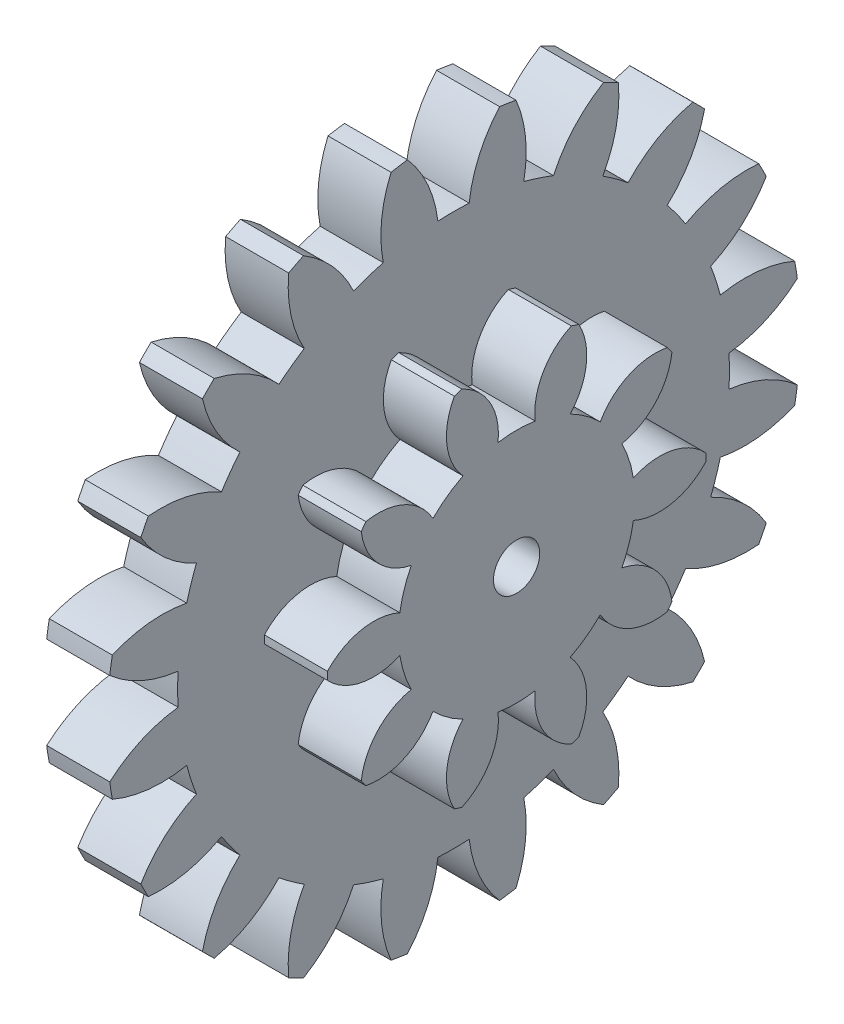
from build123d import *

# Parameters (mm, degrees)
SKETCH1_W                      = 3
SKETCH1_H                      = 16.5
CUT_EXTRUDE1_DEPTH             = 4
CUT_EXTRUDE2_DEPTH             = 4
CUT_EXTRUDE3_DEPTH             = 4
CUT_EXTRUDE4_DEPTH             = 4
CUT_EXTRUDE5_DEPTH             = 4
CUT_EXTRUDE6_DEPTH             = 4
CUT_EXTRUDE7_DEPTH             = 4
CUT_EXTRUDE8_DEPTH             = 4
CUT_EXTRUDE9_DEPTH             = 4
CUT_EXTRUDE10_DEPTH            = 4
CUT_EXTRUDE11_DEPTH            = 4
CUT_EXTRUDE12_DEPTH            = 4
CUT_EXTRUDE13_DEPTH            = 4
CUT_EXTRUDE14_DEPTH            = 4
CUT_EXTRUDE15_DEPTH            = 4
CUT_EXTRUDE16_DEPTH            = 4
CUT_EXTRUDE17_DEPTH            = 4
CUT_EXTRUDE18_DEPTH            = 4
CUT_EXTRUDE19_DEPTH            = 4
CUT_EXTRUDE20_DEPTH            = 4
BOSS_EXTRUDE1_DEPTH            = 3
F_2_2_2_2_DIAMETER_HOLE1_D     = 2.2
F_2_2_2_2_DIAMETER_HOLE1_DEPTH = 6


with BuildPart() as part:
    # Sketch1 → Revolve1 (revolve)
    with BuildSketch(Plane(origin=(0, 0, 4.89859854), x_dir=(-1, 0, 0), z_dir=(0, 0, -1))):
        with Locations((10.667145612, 10.018834535)):
            Rectangle(SKETCH1_W, SKETCH1_H)
    revolve(axis=Axis((-9.167145612, 1.768834535, 4.89859854), (-1, 0, 0)))

    # Sketch2 → Cut-Extrude1 (cut, through all)
    with BuildSketch(Plane.ZY.offset(12.167145612)):
        with BuildLine():
            ThreePointArc((-11.455448356, 3.958617656), (-11.60140146, 1.768834535), (-11.455448356, -0.420948587))
            ThreePointArc((-11.455448356, -0.420948587), (-9.939531335, 0.54858378), (-8.204306335, 1.025020154))
            ThreePointArc((-8.204306335, 1.025020154), (-8.22540146, 1.768834535), (-8.204306335, 2.512648915))
            ThreePointArc((-8.204306335, 2.512648915), (-9.939531335, 2.98908529), (-11.455448356, 3.958617656))
        make_face()
    extrude(amount=-CUT_EXTRUDE1_DEPTH, mode=Mode.SUBTRACT)

    # Sketch3 → Cut-Extrude2 (cut, through all)
    with BuildSketch(Plane.ZY.offset(12.167145612)):
        with BuildLine():
            ThreePointArc((-9.978344129, 8.905120459), (-10.793833978, 6.867614942), (-11.331704526, 4.739905445))
            ThreePointArc((-11.331704526, 4.739905445), (-9.590379788, 5.193541399), (-7.792855808, 5.110445303))
            ThreePointArc((-7.792855808, 5.110445303), (-7.583067179, 5.824373569), (-7.333153239, 6.52526433))
            ThreePointArc((-7.333153239, 6.52526433), (-8.836223347, 7.514596263), (-9.978344129, 8.905120459))
        make_face()
    extrude(amount=-CUT_EXTRUDE2_DEPTH, mode=Mode.SUBTRACT)

    # Sketch4 → Cut-Extrude3 (cut, through all)
    with BuildSketch(Plane.ZY.offset(12.167145612)):
        with BuildLine():
            ThreePointArc((-7.044981101, 13.153073875), (-8.450181867, 11.467291197), (-9.61922555, 9.609930356))
            ThreePointArc((-9.61922555, 9.609930356), (-7.822946092, 9.503264849), (-6.139077303, 8.868770308))
            ThreePointArc((-6.139077303, 8.868770308), (-5.718940494, 9.482928186), (-5.264671056, 10.072287257))
            ThreePointArc((-5.264671056, 10.072287257), (-6.388455296, 11.477672045), (-7.044981101, 13.153073875))
        make_face()
    extrude(amount=-CUT_EXTRUDE3_DEPTH, mode=Mode.SUBTRACT)

    # Sketch5 → Cut-Extrude4 (cut, through all)
    with BuildSketch(Plane.ZY.offset(12.167145612)):
        with BuildLine():
            ThreePointArc((-2.942497281, 16.286658625), (-4.799858122, 15.117614942), (-6.4856408, 13.712414176))
            ThreePointArc((-6.4856408, 13.712414176), (-4.81023897, 13.055888371), (-3.404854182, 11.932104131))
            ThreePointArc((-3.404854182, 11.932104131), (-2.815495111, 12.386373569), (-2.201337233, 12.806510377))
            ThreePointArc((-2.201337233, 12.806510377), (-2.835831774, 14.490379167), (-2.942497281, 16.286658625))
        make_face()
    extrude(amount=-CUT_EXTRUDE4_DEPTH, mode=Mode.SUBTRACT)

    # Sketch6 → Cut-Extrude5 (cut, through all)
    with BuildSketch(Plane.ZY.offset(12.167145612)):
        with BuildLine():
            ThreePointArc((1.92752763, 17.999137601), (-0.200181867, 17.461267053), (-2.237687384, 16.645777204))
            ThreePointArc((-2.237687384, 16.645777204), (-0.847163188, 15.503656422), (0.142168745, 14.000586314))
            ThreePointArc((0.142168745, 14.000586314), (0.843059506, 14.250500254), (1.556987772, 14.460288883))
            ThreePointArc((1.556987772, 14.460288883), (1.473891676, 16.257812863), (1.92752763, 17.999137601))
        make_face()
    extrude(amount=-CUT_EXTRUDE5_DEPTH, mode=Mode.SUBTRACT)

    # Sketch7 → Cut-Extrude6 (cut, through all)
    with BuildSketch(Plane.ZY.offset(12.167145612)):
        with BuildLine():
            ThreePointArc((7.088381662, 18.122881431), (4.89859854, 18.268834535), (2.708815419, 18.122881431))
            ThreePointArc((2.708815419, 18.122881431), (3.678347785, 16.60696441), (4.15478416, 14.87173941))
            ThreePointArc((4.15478416, 14.87173941), (4.89859854, 14.892834535), (5.642412921, 14.87173941))
            ThreePointArc((5.642412921, 14.87173941), (6.118849295, 16.60696441), (7.088381662, 18.122881431))
        make_face()
    extrude(amount=-CUT_EXTRUDE6_DEPTH, mode=Mode.SUBTRACT)

    # Sketch8 → Cut-Extrude7 (cut, through all)
    with BuildSketch(Plane.ZY.offset(12.167145612)):
        with BuildLine():
            ThreePointArc((12.034884465, 16.645777204), (9.997378948, 17.461267053), (7.869669451, 17.999137601))
            ThreePointArc((7.869669451, 17.999137601), (8.323305405, 16.257812863), (8.240209309, 14.460288883))
            ThreePointArc((8.240209309, 14.460288883), (8.954137575, 14.250500254), (9.655028336, 14.000586314))
            ThreePointArc((9.655028336, 14.000586314), (10.644360269, 15.503656422), (12.034884465, 16.645777204))
        make_face()
    extrude(amount=-CUT_EXTRUDE7_DEPTH, mode=Mode.SUBTRACT)

    # Sketch9 → Cut-Extrude8 (cut, through all)
    with BuildSketch(Plane.ZY.offset(12.167145612)):
        with BuildLine():
            ThreePointArc((16.282837881, 13.712414176), (14.597055203, 15.117614942), (12.739694362, 16.286658625))
            ThreePointArc((12.739694362, 16.286658625), (12.633028855, 14.490379167), (11.998534314, 12.806510377))
            ThreePointArc((11.998534314, 12.806510377), (12.612692192, 12.386373569), (13.202051263, 11.932104131))
            ThreePointArc((13.202051263, 11.932104131), (14.607436051, 13.055888371), (16.282837881, 13.712414176))
        make_face()
    extrude(amount=-CUT_EXTRUDE8_DEPTH, mode=Mode.SUBTRACT)

    # Sketch10 → Cut-Extrude9 (cut, through all)
    with BuildSketch(Plane.ZY.offset(12.167145612)):
        with BuildLine():
            ThreePointArc((19.416422631, 9.609930356), (18.247378948, 11.467291197), (16.842178182, 13.153073875))
            ThreePointArc((16.842178182, 13.153073875), (16.185652377, 11.477672045), (15.061868137, 10.072287257))
            ThreePointArc((15.061868137, 10.072287257), (15.516137575, 9.482928186), (15.936274383, 8.868770308))
            ThreePointArc((15.936274383, 8.868770308), (17.620143173, 9.503264849), (19.416422631, 9.609930356))
        make_face()
    extrude(amount=-CUT_EXTRUDE9_DEPTH, mode=Mode.SUBTRACT)

    # Sketch11 → Cut-Extrude10 (cut, through all)
    with BuildSketch(Plane.ZY.offset(12.167145612)):
        with BuildLine():
            ThreePointArc((21.128901607, 4.739905445), (20.591031059, 6.867614942), (19.77554121, 8.905120459))
            ThreePointArc((19.77554121, 8.905120459), (18.633420428, 7.514596263), (17.13035032, 6.52526433))
            ThreePointArc((17.13035032, 6.52526433), (17.38026426, 5.824373569), (17.590052889, 5.110445303))
            ThreePointArc((17.590052889, 5.110445303), (19.387576869, 5.193541399), (21.128901607, 4.739905445))
        make_face()
    extrude(amount=-CUT_EXTRUDE10_DEPTH, mode=Mode.SUBTRACT)

    # Sketch12 → Cut-Extrude11 (cut, through all)
    with BuildSketch(Plane.ZY.offset(12.167145612)):
        with BuildLine():
            ThreePointArc((21.252645437, -0.420948587), (21.39859854, 1.768834535), (21.252645437, 3.958617656))
            ThreePointArc((21.252645437, 3.958617656), (19.736728416, 2.98908529), (18.001503416, 2.512648915))
            ThreePointArc((18.001503416, 2.512648915), (18.02259854, 1.768834535), (18.001503416, 1.025020154))
            ThreePointArc((18.001503416, 1.025020154), (19.736728416, 0.54858378), (21.252645437, -0.420948587))
        make_face()
    extrude(amount=-CUT_EXTRUDE11_DEPTH, mode=Mode.SUBTRACT)

    # Sketch13 → Cut-Extrude12 (cut, through all)
    with BuildSketch(Plane.ZY.offset(12.167145612)):
        with BuildLine():
            ThreePointArc((19.77554121, -5.36745139), (20.591031059, -3.329945873), (21.128901607, -1.202236376))
            ThreePointArc((21.128901607, -1.202236376), (19.387576869, -1.65587233), (17.590052889, -1.572776234))
            ThreePointArc((17.590052889, -1.572776234), (17.38026426, -2.2867045), (17.13035032, -2.987595261))
            ThreePointArc((17.13035032, -2.987595261), (18.633420428, -3.976927194), (19.77554121, -5.36745139))
        make_face()
    extrude(amount=-CUT_EXTRUDE12_DEPTH, mode=Mode.SUBTRACT)

    # Sketch14 → Cut-Extrude13 (cut, through all)
    with BuildSketch(Plane.ZY.offset(12.167145612)):
        with BuildLine():
            ThreePointArc((16.842178182, -9.615404806), (18.247378948, -7.929622128), (19.416422631, -6.072261287))
            ThreePointArc((19.416422631, -6.072261287), (17.620143173, -5.96559578), (15.936274383, -5.331101239))
            ThreePointArc((15.936274383, -5.331101239), (15.516137575, -5.945259117), (15.061868137, -6.534618188))
            ThreePointArc((15.061868137, -6.534618188), (16.185652377, -7.940002976), (16.842178182, -9.615404806))
        make_face()
    extrude(amount=-CUT_EXTRUDE13_DEPTH, mode=Mode.SUBTRACT)

    # Sketch15 → Cut-Extrude14 (cut, through all)
    with BuildSketch(Plane.ZY.offset(12.167145612)):
        with BuildLine():
            ThreePointArc((12.739694362, -12.748989556), (14.597055203, -11.579945873), (16.282837881, -10.174745107))
            ThreePointArc((16.282837881, -10.174745107), (14.607436051, -9.518219302), (13.202051263, -8.394435062))
            ThreePointArc((13.202051263, -8.394435062), (12.612692192, -8.8487045), (11.998534314, -9.268841308))
            ThreePointArc((11.998534314, -9.268841308), (12.633028855, -10.952710098), (12.739694362, -12.748989556))
        make_face()
    extrude(amount=-CUT_EXTRUDE14_DEPTH, mode=Mode.SUBTRACT)

    # Sketch16 → Cut-Extrude15 (cut, through all)
    with BuildSketch(Plane.ZY.offset(12.167145612)):
        with BuildLine():
            ThreePointArc((7.869669451, -14.461468532), (9.997378948, -13.923597984), (12.034884465, -13.108108135))
            ThreePointArc((12.034884465, -13.108108135), (10.644360269, -11.965987353), (9.655028336, -10.462917245))
            ThreePointArc((9.655028336, -10.462917245), (8.954137575, -10.712831185), (8.240209309, -10.922619814))
            ThreePointArc((8.240209309, -10.922619814), (8.323305405, -12.720143794), (7.869669451, -14.461468532))
        make_face()
    extrude(amount=-CUT_EXTRUDE15_DEPTH, mode=Mode.SUBTRACT)

    # Sketch17 → Cut-Extrude16 (cut, through all)
    with BuildSketch(Plane.ZY.offset(12.167145612)):
        with BuildLine():
            ThreePointArc((2.708815419, -14.585212362), (4.89859854, -14.731165465), (7.088381662, -14.585212362))
            ThreePointArc((7.088381662, -14.585212362), (6.118849295, -13.069295341), (5.642412921, -11.334070341))
            ThreePointArc((5.642412921, -11.334070341), (4.89859854, -11.355165465), (4.15478416, -11.334070341))
            ThreePointArc((4.15478416, -11.334070341), (3.678347785, -13.069295341), (2.708815419, -14.585212362))
        make_face()
    extrude(amount=-CUT_EXTRUDE16_DEPTH, mode=Mode.SUBTRACT)

    # Sketch18 → Cut-Extrude17 (cut, through all)
    with BuildSketch(Plane.ZY.offset(12.167145612)):
        with BuildLine():
            ThreePointArc((-2.237687384, -13.108108135), (-0.200181867, -13.923597984), (1.92752763, -14.461468532))
            ThreePointArc((1.92752763, -14.461468532), (1.473891676, -12.720143794), (1.556987772, -10.922619814))
            ThreePointArc((1.556987772, -10.922619814), (0.843059506, -10.712831185), (0.142168745, -10.462917245))
            ThreePointArc((0.142168745, -10.462917245), (-0.847163188, -11.965987353), (-2.237687384, -13.108108135))
        make_face()
    extrude(amount=-CUT_EXTRUDE17_DEPTH, mode=Mode.SUBTRACT)

    # Sketch19 → Cut-Extrude18 (cut, through all)
    with BuildSketch(Plane.ZY.offset(12.167145612)):
        with BuildLine():
            ThreePointArc((-6.4856408, -10.174745107), (-4.799858122, -11.579945873), (-2.942497281, -12.748989556))
            ThreePointArc((-2.942497281, -12.748989556), (-2.835831774, -10.952710098), (-2.201337233, -9.268841308))
            ThreePointArc((-2.201337233, -9.268841308), (-2.815495111, -8.8487045), (-3.404854182, -8.394435062))
            ThreePointArc((-3.404854182, -8.394435062), (-4.81023897, -9.518219302), (-6.4856408, -10.174745107))
        make_face()
    extrude(amount=-CUT_EXTRUDE18_DEPTH, mode=Mode.SUBTRACT)

    # Sketch20 → Cut-Extrude19 (cut, through all)
    with BuildSketch(Plane.ZY.offset(12.167145612)):
        with BuildLine():
            ThreePointArc((-9.61922555, -6.072261287), (-8.450181867, -7.929622128), (-7.044981101, -9.615404806))
            ThreePointArc((-7.044981101, -9.615404806), (-6.388455296, -7.940002976), (-5.264671056, -6.534618188))
            ThreePointArc((-5.264671056, -6.534618188), (-5.718940494, -5.945259117), (-6.139077303, -5.331101239))
            ThreePointArc((-6.139077303, -5.331101239), (-7.822946092, -5.96559578), (-9.61922555, -6.072261287))
        make_face()
    extrude(amount=-CUT_EXTRUDE19_DEPTH, mode=Mode.SUBTRACT)

    # Sketch21 → Cut-Extrude20 (cut, through all)
    with BuildSketch(Plane.ZY.offset(12.167145612)):
        with BuildLine():
            ThreePointArc((-11.331704526, -1.202236376), (-10.793833978, -3.329945873), (-9.978344129, -5.36745139))
            ThreePointArc((-9.978344129, -5.36745139), (-8.836223347, -3.976927194), (-7.333153239, -2.987595261))
            ThreePointArc((-7.333153239, -2.987595261), (-7.583067179, -2.2867045), (-7.792855808, -1.572776234))
            ThreePointArc((-7.792855808, -1.572776234), (-9.590379788, -1.65587233), (-11.331704526, -1.202236376))
        make_face()
    extrude(amount=-CUT_EXTRUDE20_DEPTH, mode=Mode.SUBTRACT)

    # Sketch22 → Boss-Extrude1 (add)
    with BuildSketch(Plane(origin=(-9.167145612, 0, 0), x_dir=(0, 0, -1), z_dir=(1, 0, 0))):
        with BuildLine():
            ThreePointArc((-9.907737373, -0.788098034), (-10.247340388, 0.030922958), (-10.454004238, 0.893138504))
            ThreePointArc((-10.454004238, 0.893138504), (-12.286626448, 0.681374971), (-13.896659241, 1.582009394))
            ThreePointArc((-13.896659241, 1.582009394), (-13.89859854, 1.768834535), (-13.896659241, 1.955659676))
            ThreePointArc((-13.896659241, 1.955659676), (-12.286626448, 2.856294098), (-10.454004238, 2.644530566))
            ThreePointArc((-10.454004238, 2.644530566), (-10.247340388, 3.506746111), (-9.907737373, 4.325767103))
            ThreePointArc((-9.907737373, 4.325767103), (-11.514831366, 5.231635115), (-12.287995626, 6.906617199))
            ThreePointArc((-12.287995626, 6.906617199), (-12.17975149, 7.058901805), (-12.068369501, 7.208906627))
            ThreePointArc((-12.068369501, 7.208906627), (-10.236445978, 6.991181649), (-8.878294948, 5.742673045))
            ThreePointArc((-8.878294948, 5.742673045), (-8.204302799, 6.318746111), (-7.448149728, 6.781734368))
            ThreePointArc((-7.448149728, 6.781734368), (-8.215860223, 8.459223132), (-7.856833481, 10.268766654))
            ThreePointArc((-7.856833481, 10.268766654), (-7.67975149, 10.328343181), (-7.501470946, 10.384230941))
            ThreePointArc((-7.501470946, 10.384230941), (-6.147389215, 9.131310104), (-5.782476895, 7.322944279))
            ThreePointArc((-5.782476895, 7.322944279), (-4.89859854, 7.392834535), (-4.014720186, 7.322944279))
            ThreePointArc((-4.014720186, 7.322944279), (-3.649807866, 9.131310104), (-2.295726135, 10.384230941))
            ThreePointArc((-2.295726135, 10.384230941), (-2.117445591, 10.328343181), (-1.9403636, 10.268766654))
            ThreePointArc((-1.9403636, 10.268766654), (-1.581336858, 8.459223132), (-2.349047353, 6.781734368))
            ThreePointArc((-2.349047353, 6.781734368), (-1.592894282, 6.318746111), (-0.918902133, 5.742673045))
            ThreePointArc((-0.918902133, 5.742673045), (0.439248898, 6.991181649), (2.27117242, 7.208906627))
            ThreePointArc((2.27117242, 7.208906627), (2.382554409, 7.058901805), (2.490798545, 6.906617199))
            ThreePointArc((2.490798545, 6.906617199), (1.717634285, 5.231635115), (0.110540292, 4.325767103))
            ThreePointArc((0.110540292, 4.325767103), (0.450143307, 3.506746111), (0.656807157, 2.644530566))
            ThreePointArc((0.656807157, 2.644530566), (2.489429367, 2.856294098), (4.09946216, 1.955659676))
            ThreePointArc((4.09946216, 1.955659676), (4.10140146, 1.768834535), (4.09946216, 1.582009394))
            ThreePointArc((4.09946216, 1.582009394), (2.489429367, 0.681374971), (0.656807157, 0.893138504))
            ThreePointArc((0.656807157, 0.893138504), (0.450143307, 0.030922958), (0.110540292, -0.788098034))
            ThreePointArc((0.110540292, -0.788098034), (1.717634285, -1.693966045), (2.490798545, -3.36894813))
            ThreePointArc((2.490798545, -3.36894813), (2.382554409, -3.521232736), (2.27117242, -3.671237558))
            ThreePointArc((2.27117242, -3.671237558), (0.439248898, -3.45351258), (-0.918902133, -2.205003976))
            ThreePointArc((-0.918902133, -2.205003976), (-1.592894282, -2.781077042), (-2.349047353, -3.244065299))
            ThreePointArc((-2.349047353, -3.244065299), (-1.581336858, -4.921554063), (-1.9403636, -6.731097585))
            ThreePointArc((-1.9403636, -6.731097585), (-2.117445591, -6.790674112), (-2.295726135, -6.846561872))
            ThreePointArc((-2.295726135, -6.846561872), (-3.649807866, -5.593641035), (-4.014720186, -3.78527521))
            ThreePointArc((-4.014720186, -3.78527521), (-4.89859854, -3.855165465), (-5.782476895, -3.78527521))
            ThreePointArc((-5.782476895, -3.78527521), (-6.147389215, -5.593641035), (-7.501470946, -6.846561872))
            ThreePointArc((-7.501470946, -6.846561872), (-7.67975149, -6.790674112), (-7.856833481, -6.731097585))
            ThreePointArc((-7.856833481, -6.731097585), (-8.215860223, -4.921554063), (-7.448149728, -3.244065299))
            ThreePointArc((-7.448149728, -3.244065299), (-8.204302799, -2.781077042), (-8.878294948, -2.205003976))
            ThreePointArc((-8.878294948, -2.205003976), (-10.236445978, -3.45351258), (-12.068369501, -3.671237558))
            ThreePointArc((-12.068369501, -3.671237558), (-12.17975149, -3.521232736), (-12.287995626, -3.36894813))
            ThreePointArc((-12.287995626, -3.36894813), (-11.514831366, -1.693966045), (-9.907737373, -0.788098034))
        make_face()
    extrude(amount=BOSS_EXTRUDE1_DEPTH)

    # Ø2.2 (2.2) Diameter Hole1
    with Locations(Plane.ZY.offset(12.167145612)):
        with Locations((4.89859854, 1.768834535)):
            Hole(F_2_2_2_2_DIAMETER_HOLE1_D / 2, depth=F_2_2_2_2_DIAMETER_HOLE1_DEPTH)


solid = part.part
